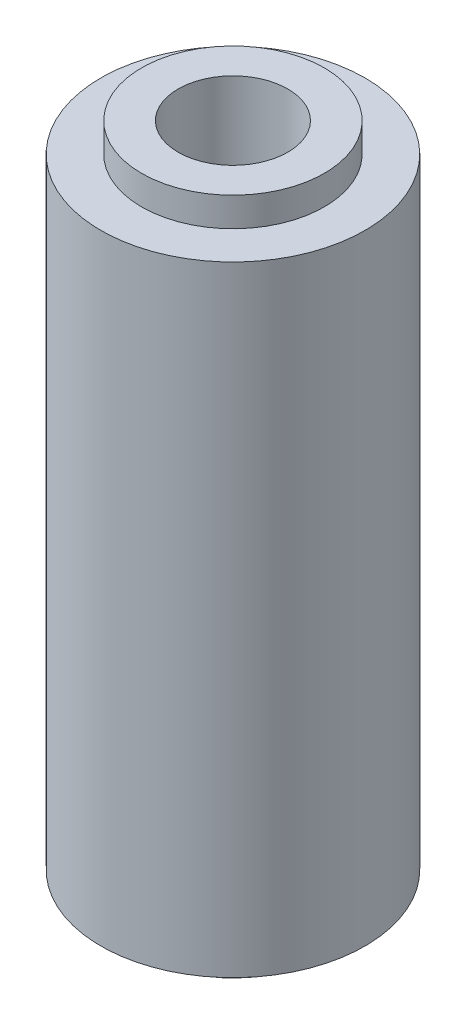
from build123d import *

# Parameters (mm, degrees)
SKETCH2_R                = 3.9751
BOSS_EXTRUDE1_DEPTH      = 9.525
M4X0_7_TAPPED_HOLE1_D    = 3.3
SKETCH5_R                = 2.75
SKETCH5_R_2              = 1.65
BOSS_EXTRUDE2_DEPTH      = 0.675
BOSS_EXTRUDE2_DEPTH_BACK = 19.725
SKETCH6_R                = 3.9751
SKETCH6_R_2              = 2.75
CUT_EXTRUDE1_DEPTH       = 0.2
SKETCH7_R                = 3.9751
SKETCH7_R_2              = 2.75
CUT_EXTRUDE2_DEPTH       = 0.2


with BuildPart() as part:
    # Sketch2 → Boss-Extrude1 (new, symmetric)
    with BuildSketch(Plane(origin=(0, 0, 0), x_dir=(1, 0, 0), z_dir=(0, 1, 0))):
        with Locations(Location((0, 0, 0), (0, 0, 90))):
            Circle(SKETCH2_R)
    extrude(amount=BOSS_EXTRUDE1_DEPTH, both=True)

    # M4x0.7 Tapped Hole1 (through all)
    with Locations(Plane(origin=(0, 9.525, 0), x_dir=(1, 0, 0), z_dir=(0, 1, 0))):
        with Locations((0, 0)):
            Hole(M4X0_7_TAPPED_HOLE1_D / 2)

    # Sketch5 → Boss-Extrude2 (add, two sides)
    with BuildSketch(Plane(origin=(0, 9.525, 0), x_dir=(1, 0, 0), z_dir=(0, 1, 0))) as boss_extrude2_sk:
        with Locations(Location((0, 0, 0), (0, 0, 270))):
            Circle(SKETCH5_R)
        with Locations(Location((0, 0, 0), (0, 0, 270))):
            Circle(SKETCH5_R_2, mode=Mode.SUBTRACT)
    extrude(amount=BOSS_EXTRUDE2_DEPTH)
    extrude(boss_extrude2_sk.sketch, amount=-BOSS_EXTRUDE2_DEPTH_BACK)

    # Sketch6 → Cut-Extrude1 (cut)
    with BuildSketch(Plane(origin=(0, 9.525, 0), x_dir=(1, 0, 0), z_dir=(0, 1, 0))):
        with Locations(Location((0, 0, 0), (0, 0, 90))):
            Circle(SKETCH6_R)
        with Locations(Location((0, 0, 0), (0, 0, 270))):
            Circle(SKETCH6_R_2, mode=Mode.SUBTRACT)
    extrude(amount=-CUT_EXTRUDE1_DEPTH, mode=Mode.SUBTRACT)

    # Sketch7 → Cut-Extrude2 (cut)
    with BuildSketch(Plane.XZ.offset(9.525)):
        with Locations(Location((0, 0, 0), (0, 0, 270))):
            Circle(SKETCH7_R)
        with Locations(Location((0, 0, 0), (0, 0, 90))):
            Circle(SKETCH7_R_2, mode=Mode.SUBTRACT)
    extrude(amount=-CUT_EXTRUDE2_DEPTH, mode=Mode.SUBTRACT)


solid = part.part
